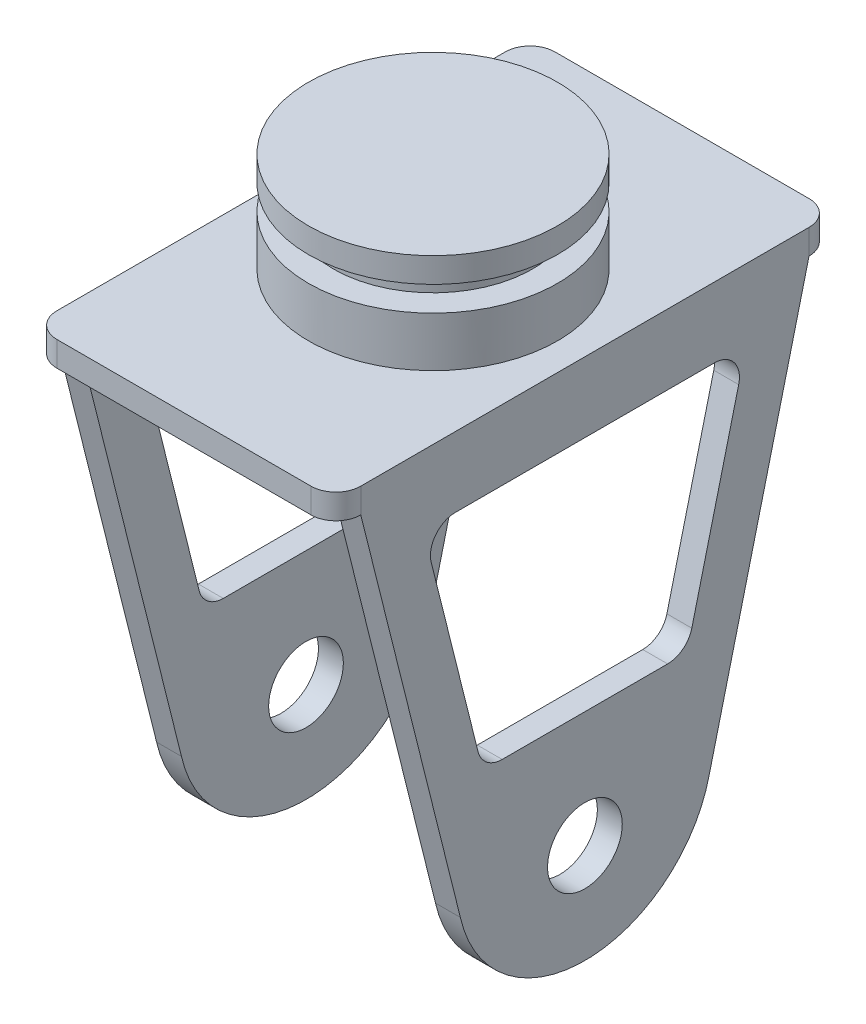
from build123d import *

# Parameters (mm, degrees)
BOSS_EXTRUDE1_DEPTH = 2.54
SKETCH2_R           = 12.7
BOSS_EXTRUDE2_DEPTH = 5.08
SKETCH3_R           = 10.16
BOSS_EXTRUDE3_DEPTH = 2.54
SKETCH4_R           = 12.7
BOSS_EXTRUDE4_DEPTH = 2.54
SKETCH5_W           = 2.54
SKETCH5_H           = 45.72
BOSS_EXTRUDE5_DEPTH = 50.8
SKETCH6_R           = 3.81
CUT_EXTRUDE1_DEPTH  = 2.54
SKETCH6_3_R         = 3.81
CUT_EXTRUDE2_DEPTH  = 30.988
CUT_EXTRUDE3_DEPTH  = 65.699738361


with BuildPart() as part:
    # Sketch1 → Boss-Extrude1 (new body)
    with BuildSketch(Plane(origin=(0, 0, 0), x_dir=(1, 0, 0), z_dir=(0, 1, 0))):
        with BuildLine():
            Line((-12.954, -25.4), (12.954, -25.4))
            ThreePointArc((12.954, -25.4), (14.750051224, -24.656051224), (15.494, -22.86))
            Line((15.494, -22.86), (15.494, 22.86))
            ThreePointArc((15.494, 22.86), (14.750051224, 24.656051224), (12.954, 25.4))
            Line((12.954, 25.4), (-12.954, 25.4))
            ThreePointArc((-12.954, 25.4), (-14.750051224, 24.656051224), (-15.494, 22.86))
            Line((-15.494, 22.86), (-15.494, -22.86))
            ThreePointArc((-15.494, -22.86), (-14.750051224, -24.656051224), (-12.954, -25.4))
        make_face()
    extrude(amount=BOSS_EXTRUDE1_DEPTH)

    # Sketch2 → Boss-Extrude2 (add)
    with BuildSketch(Plane(origin=(0, 2.54, 0), x_dir=(1, 0, 0), z_dir=(0, 1, 0))):
        Circle(SKETCH2_R)
    extrude(amount=BOSS_EXTRUDE2_DEPTH)

    # Sketch3 → Boss-Extrude3 (add)
    with BuildSketch(Plane(origin=(0, 7.62, 0), x_dir=(1, 0, 0), z_dir=(0, 1, 0))):
        Circle(SKETCH3_R)
    extrude(amount=BOSS_EXTRUDE3_DEPTH)

    # Sketch4 → Boss-Extrude4 (add)
    with BuildSketch(Plane(origin=(0, 10.16, 0), x_dir=(1, 0, 0), z_dir=(0, 1, 0))):
        Circle(SKETCH4_R)
    extrude(amount=BOSS_EXTRUDE4_DEPTH)

    # Sketch5 → Boss-Extrude5 (add)
    with BuildSketch(Plane.XZ):
        with Locations((-14.224, 0)):
            Rectangle(SKETCH5_W, SKETCH5_H)
        with Locations((14.224, 0)):
            Rectangle(SKETCH5_W, SKETCH5_H)
    extrude(amount=BOSS_EXTRUDE5_DEPTH)

    # Sketch6 → Cut-Extrude1 (cut)
    with BuildSketch(Plane(origin=(15.494, 0, 0), x_dir=(0, 0, -1), z_dir=(1, 0, 0))):
        with Locations((0, -40.64)):
            Circle(SKETCH6_R)
    extrude(amount=-CUT_EXTRUDE1_DEPTH, mode=Mode.SUBTRACT)

    # Sketch6_3 → Cut-Extrude2 (cut)
    with BuildSketch(Plane(origin=(15.494, 0, 0), x_dir=(0, 0, -1), z_dir=(1, 0, 0))):
        with BuildLine():
            Line((-12.7, -40.64), (-22.86, 0))
            Line((-22.86, 0), (-22.86, -50.8))
            Line((-22.86, -50.8), (9e-09, -50.8))
            ThreePointArc((9e-09, -50.8), (-8.131967778, -47.94745973), (-12.7, -40.64))
        make_face()
        with BuildLine():
            ThreePointArc((12.7, -40.64), (8.131967785, -47.947459724), (9e-09, -50.8))
            Line((9e-09, -50.8), (22.86, -50.8))
            Line((22.86, -50.8), (22.86, 0))
            Line((22.86, 0), (12.7, -40.64))
        make_face()
        with Locations((0, -40.64)):
            Circle(SKETCH6_3_R)
    extrude(amount=-CUT_EXTRUDE2_DEPTH, mode=Mode.SUBTRACT)

    # Sketch7 → Cut-Extrude3 (cut, through all)
    with BuildSketch(Plane(origin=(15.494, 0, 0), x_dir=(0, 0, -1), z_dir=(1, 0, 0))):
        with BuildLine():
            Line((-15.682995336, -7.762642077), (-10.901798835, -26.887428081))
            ThreePointArc((-10.901798835, -26.887428081), (-10.000783897, -28.273429406), (-8.437636885, -28.811387593))
            Line((-8.437636885, -28.811387593), (8.437636885, -28.811387593))
            ThreePointArc((8.437636885, -28.811387593), (10.000783897, -28.273429406), (10.901798835, -26.887428081))
            Line((10.901798835, -26.887428081), (15.682995336, -7.762642077))
            ThreePointArc((15.682995336, -7.762642077), (15.220875198, -5.583454578), (13.218833386, -4.60660159))
            Line((13.218833386, -4.60660159), (-13.218833386, -4.60660159))
            ThreePointArc((-13.218833386, -4.60660159), (-15.220875198, -5.583454578), (-15.682995336, -7.762642077))
        make_face()
    extrude(amount=-CUT_EXTRUDE3_DEPTH, mode=Mode.SUBTRACT)


solid = part.part
